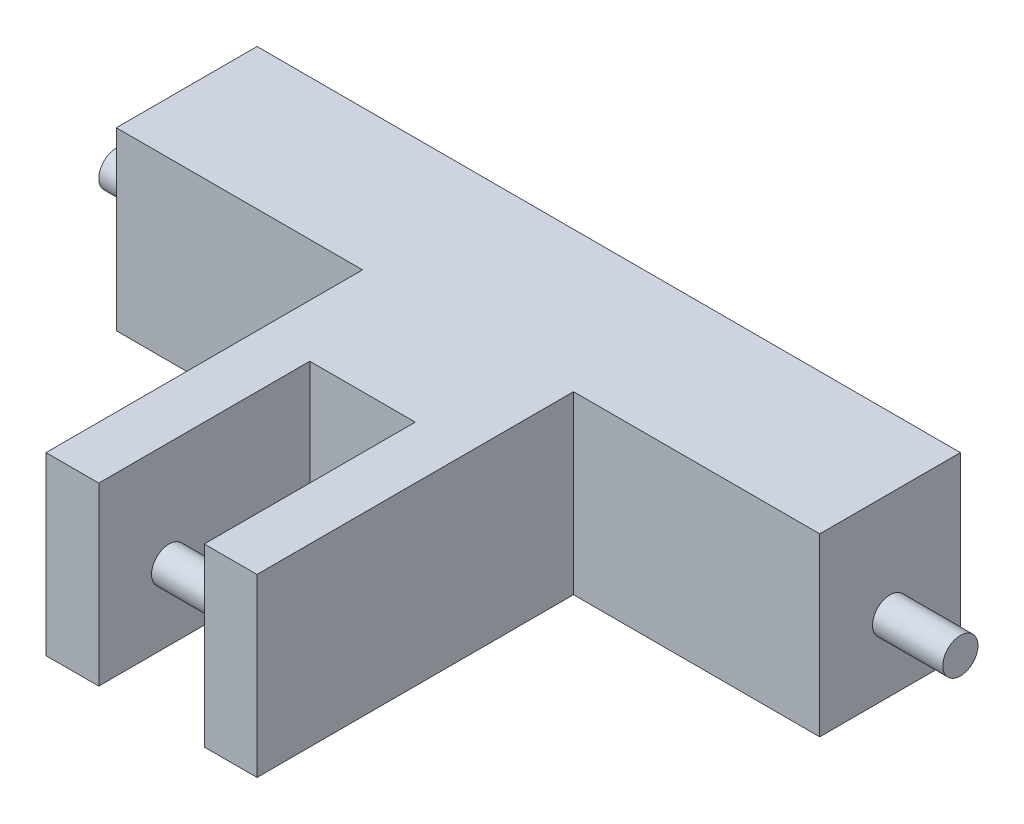
from build123d import *

# Parameters (mm, degrees)
BOSS_EXTRUDE1_DEPTH = 25
SKETCH2_W           = 15
SKETCH2_H           = 30
CUT_EXTRUDE1_DEPTH  = 30
SKETCH3_R           = 2.5
BOSS_EXTRUDE2_DEPTH = 10
BOSS_EXTRUDE3_REACH = 69.5
SKETCH5_R           = 2.5


with BuildPart() as part:
    # Sketch1 → Boss-Extrude1 (new body)
    with BuildSketch(Plane(origin=(0, 0, 0), x_dir=(1, 0, 0), z_dir=(0, 1, 0))):
        Polygon((-50, 20), (50, 20), (50, 0), (15, 0), (15, -45), (-15, -45), (-15, 0), (-50, 0), align=None)
    extrude(amount=BOSS_EXTRUDE1_DEPTH)

    # Sketch2 → Cut-Extrude1 (cut)
    with BuildSketch(Plane.XY.offset(45)):
        with Locations((0, 15)):
            Rectangle(SKETCH2_W, SKETCH2_H)
    extrude(amount=-CUT_EXTRUDE1_DEPTH, mode=Mode.SUBTRACT)

    # Sketch3 → Boss-Extrude2 (add)
    with BuildSketch(Plane(origin=(50, 0, 0), x_dir=(0, 0, -1), z_dir=(1, 0, 0))):
        with Locations((10, 10)):
            Circle(SKETCH3_R)
    boss_extrude2 = extrude(amount=BOSS_EXTRUDE2_DEPTH)

    # Mirror1: Boss-Extrude2 across plane
    add(boss_extrude2.mirror(Plane(origin=(0, 0, 0), x_dir=(0, 0, 1), z_dir=(1, 0, 0))))

    # Sketch5 → Boss-Extrude3 (add, up to next)
    with BuildSketch(Plane(origin=(-7.5, 0, 0), x_dir=(0, 0, -1), z_dir=(1, 0, 0)), mode=Mode.PRIVATE) as boss_extrude3_sk1:
        with Locations((-35, 10)):
            Circle(SKETCH5_R)
    boss_extrude3_tool1 = extrude(boss_extrude3_sk1.sketch, amount=BOSS_EXTRUDE3_REACH, mode=Mode.PRIVATE) - part.part
    add(boss_extrude3_tool1.solids().sort_by_distance((-7.5, 10, 35))[0])


solid = part.part
